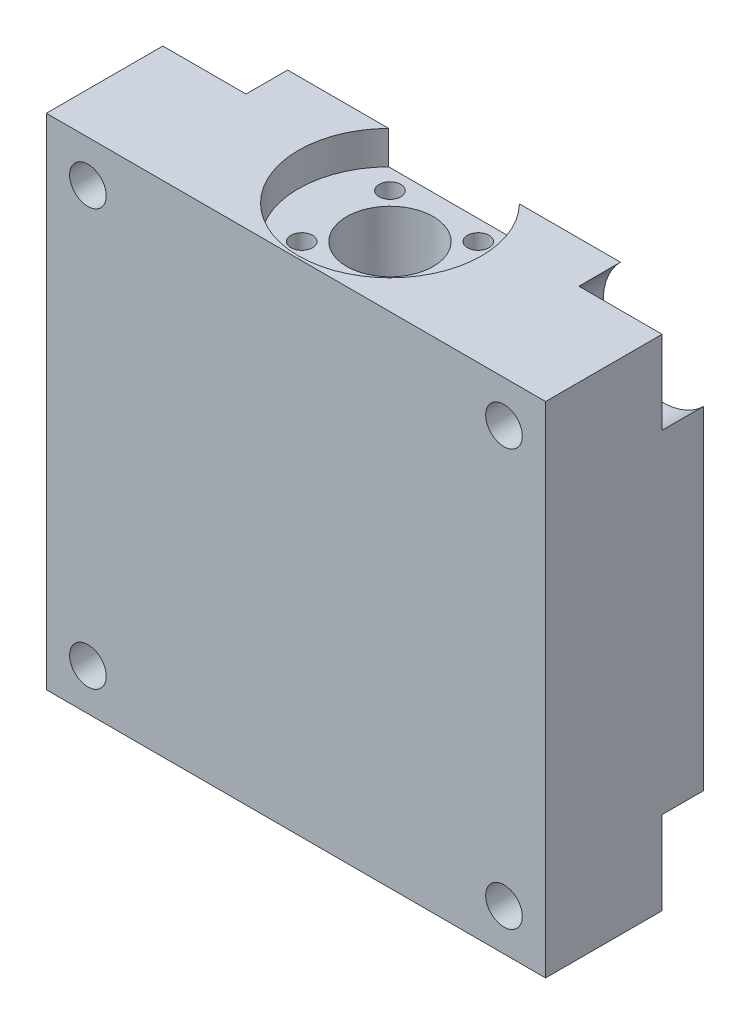
from build123d import *

# Parameters (mm, degrees)
SKETCH1_W           = 60
SKETCH1_H           = 60
SKETCH1_R           = 2.2
BOSS_EXTRUDE1_DEPTH = 19
SKETCH2_R           = 11
CUT_EXTRUDE1_DEPTH  = 4
CUT_EXTRUDE2_REACH  = 58
SKETCH3_R           = 5.2
SKETCH4_R           = 7.2
CUT_EXTRUDE3_DEPTH  = 46
SKETCH5_R           = 1.3
CUT_EXTRUDE4_DEPTH  = 6
SKETCH6_R           = 7.071067812
CUT_EXTRUDE5_DEPTH  = 5


with BuildPart() as part:
    # Sketch1 → Boss-Extrude1 (new body)
    with BuildSketch(Plane.XY):
        Rectangle(SKETCH1_W, SKETCH1_H)
        with Locations((-25, 25)):
            Circle(SKETCH1_R, mode=Mode.SUBTRACT)
        with Locations((25, 25)):
            Circle(SKETCH1_R, mode=Mode.SUBTRACT)
        with Locations((25, -25)):
            Circle(SKETCH1_R, mode=Mode.SUBTRACT)
        with Locations((-25, -25)):
            Circle(SKETCH1_R, mode=Mode.SUBTRACT)
    extrude(amount=BOSS_EXTRUDE1_DEPTH)

    # Sketch2 → Cut-Extrude1 (cut)
    with BuildSketch(Plane(origin=(0, 30, 0), x_dir=(1, 0, 0), z_dir=(0, 1, 0))):
        with Locations((0, -7.7)):
            Circle(SKETCH2_R)
    extrude(amount=-CUT_EXTRUDE1_DEPTH, mode=Mode.SUBTRACT)

    # Sketch3 → Cut-Extrude2 (cut, up to next)
    with BuildSketch(Plane(origin=(0, 26, 0), x_dir=(1, 0, 0), z_dir=(0, 1, 0)), mode=Mode.PRIVATE) as cut_extrude2_sk1:
        with Locations((0, -7.7)):
            Circle(SKETCH3_R)
    cut_extrude2_tool1 = extrude(cut_extrude2_sk1.sketch, amount=-CUT_EXTRUDE2_REACH, mode=Mode.PRIVATE) & part.part
    add(cut_extrude2_tool1.solids().sort_by_distance((0, 26, 7.7))[0], mode=Mode.SUBTRACT)

    # Sketch4 → Cut-Extrude3 (cut)
    with BuildSketch(Plane.XZ.offset(30)):
        with Locations((0, 7.7)):
            Circle(SKETCH4_R)
    extrude(amount=-CUT_EXTRUDE3_DEPTH, mode=Mode.SUBTRACT)

    # Sketch5 → Cut-Extrude4 (cut)
    with BuildSketch(Plane(origin=(0, 26, 0), x_dir=(1, 0, 0), z_dir=(0, 1, 0))):
        with Locations((-5.303300859, -2.396699141)):
            Circle(SKETCH5_R)
        with Locations((5.303300859, -2.396699141)):
            Circle(SKETCH5_R)
        with Locations((5.303300859, -13.003300859)):
            Circle(SKETCH5_R)
        with Locations((-5.303300859, -13.003300859)):
            Circle(SKETCH5_R)
    extrude(amount=-CUT_EXTRUDE4_DEPTH, mode=Mode.SUBTRACT)

    # Sketch6 → Cut-Extrude5 (cut)
    with BuildSketch(Plane(origin=(0, 0, 0), x_dir=(-1, 0, 0), z_dir=(0, 0, -1))):
        with Locations((-25, 25)):
            Circle(SKETCH6_R)
        with Locations((25, 25)):
            Circle(SKETCH6_R)
        with Locations((25, -25)):
            Circle(SKETCH6_R)
        with Locations((-25, -25)):
            Circle(SKETCH6_R)
    extrude(amount=-CUT_EXTRUDE5_DEPTH, mode=Mode.SUBTRACT)


solid = part.part
